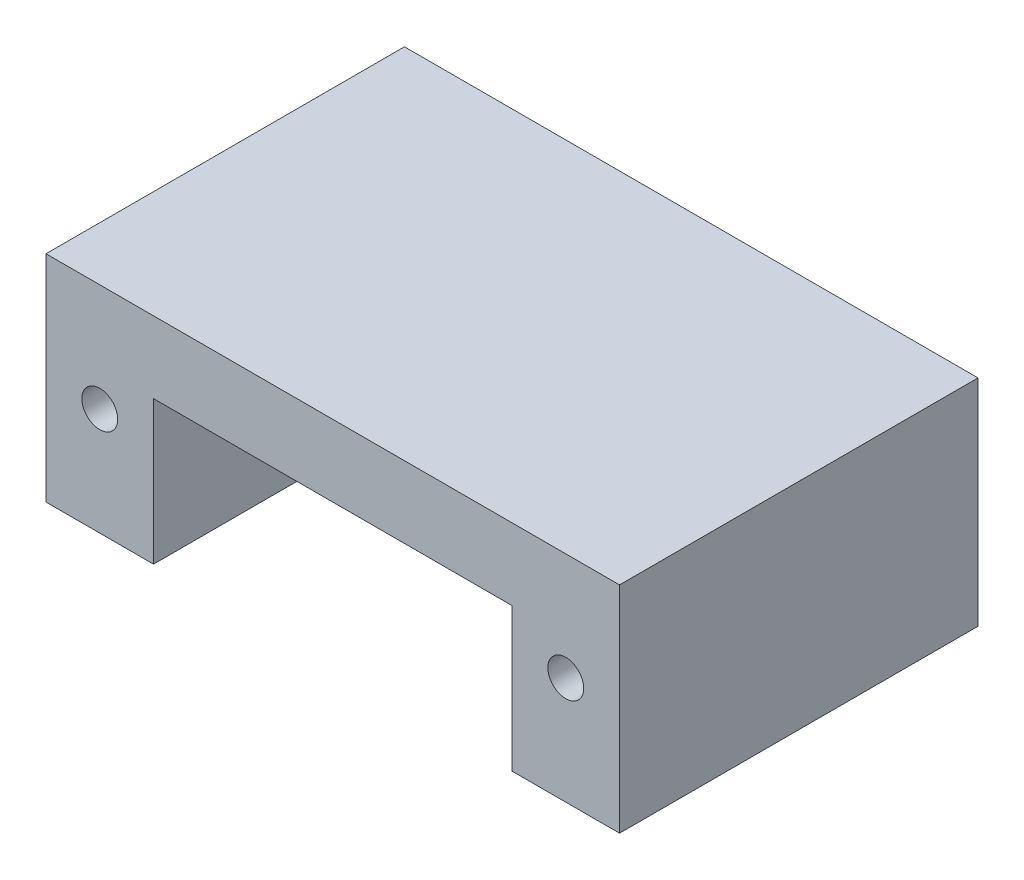
from build123d import *

# Parameters (mm, degrees)
SKETCH1_W           = 80
SKETCH1_H           = 30
BOSS_EXTRUDE1_DEPTH = 50
SKETCH2_W           = 50
SKETCH2_H           = 20
CUT_EXTRUDE1_DEPTH  = 50
SKETCH3_R           = 2.5
CUT_EXTRUDE2_DEPTH  = 50


with BuildPart() as part:
    # Sketch1 → Boss-Extrude1 (new body)
    with BuildSketch(Plane.XY):
        Rectangle(SKETCH1_W, SKETCH1_H)
    extrude(amount=BOSS_EXTRUDE1_DEPTH)

    # Sketch2 → Cut-Extrude1 (cut)
    with BuildSketch(Plane.XY.offset(50)):
        with Locations((0, -5)):
            Rectangle(SKETCH2_W, SKETCH2_H)
    extrude(amount=-CUT_EXTRUDE1_DEPTH, mode=Mode.SUBTRACT)

    # Sketch3 → Cut-Extrude2 (cut)
    with BuildSketch(Plane.XY.offset(50)):
        with Locations((-32.5, 0)):
            Circle(SKETCH3_R)
        with Locations((32.5, 0)):
            Circle(SKETCH3_R)
    extrude(amount=-CUT_EXTRUDE2_DEPTH, mode=Mode.SUBTRACT)


solid = part.part
